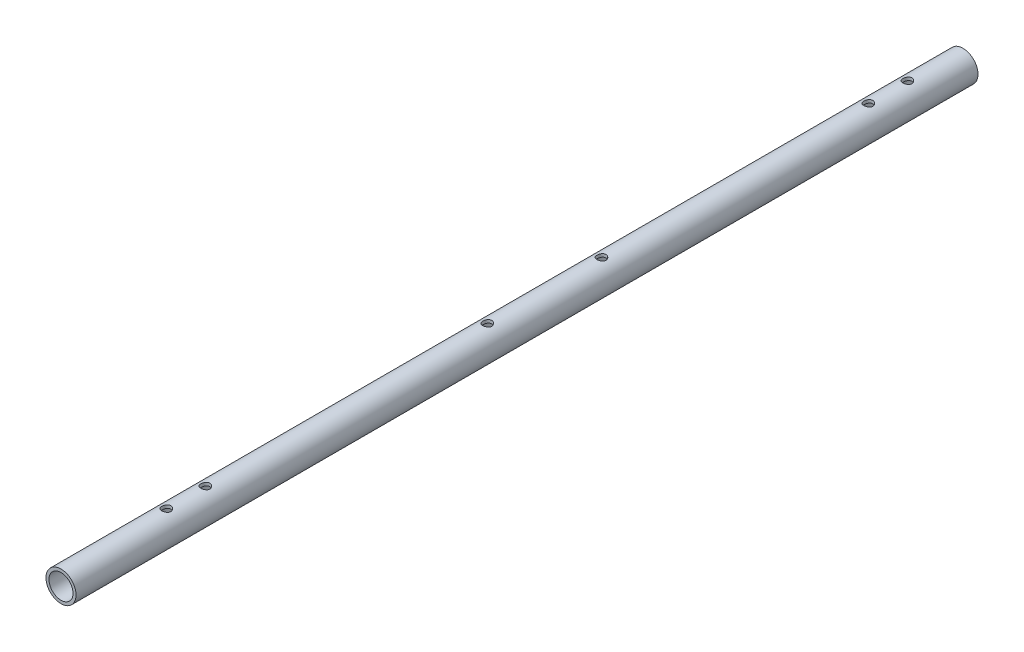
from build123d import *

# Parameters (mm, degrees)
SKETCH_1_R               = 5
SKETCH_1_R_2             = 4
EXTRUDE_1_DEPTH          = 150
SKETCH_2_R               = 1.5
CUT_EXTRUDE_1_DEPTH      = 6
CUT_EXTRUDE_1_DEPTH_BACK = 6
SKETCH_3_R               = 1.5
CUT_EXTRUDE_2_DEPTH      = 6.000000124
CUT_EXTRUDE_2_DEPTH_BACK = 6.000000124


with BuildPart() as part:
    # 草图1 → 拉伸-薄壁1 (new body, symmetric)
    with BuildSketch(Plane.XY):
        Circle(SKETCH_1_R)
        Circle(SKETCH_1_R_2, mode=Mode.SUBTRACT)
    extrude(amount=EXTRUDE_1_DEPTH, both=True)

    # 草图2 → 切除-拉伸1 (cut, two sides)
    with BuildSketch(Plane(origin=(0, 0, 0), x_dir=(1, 0, 0), z_dir=(0, 1, 0))) as cut_extrude_1_sk:
        with Locations((0, 29.75)):
            Circle(SKETCH_2_R)
        with Locations((0, -8.25)):
            Circle(SKETCH_2_R)
    extrude(amount=CUT_EXTRUDE_1_DEPTH, mode=Mode.SUBTRACT)
    extrude(cut_extrude_1_sk.sketch, amount=-CUT_EXTRUDE_1_DEPTH_BACK, mode=Mode.SUBTRACT)

    # 草图3 → 切除-拉伸2 (cut, two sides)
    with BuildSketch(Plane(origin=(0, 0, 0), x_dir=(0, 0, -1), z_dir=(0, 1, 0))) as cut_extrude_2_sk:
        with Locations((118.5, 0)):
            Circle(SKETCH_3_R)
        with Locations((131.5, 0)):
            Circle(SKETCH_3_R)
        with Locations((-115, 0)):
            Circle(SKETCH_3_R)
        with Locations((-102, 0)):
            Circle(SKETCH_3_R)
    extrude(amount=CUT_EXTRUDE_2_DEPTH, mode=Mode.SUBTRACT)
    extrude(cut_extrude_2_sk.sketch, amount=-CUT_EXTRUDE_2_DEPTH_BACK, mode=Mode.SUBTRACT)


solid = part.part
